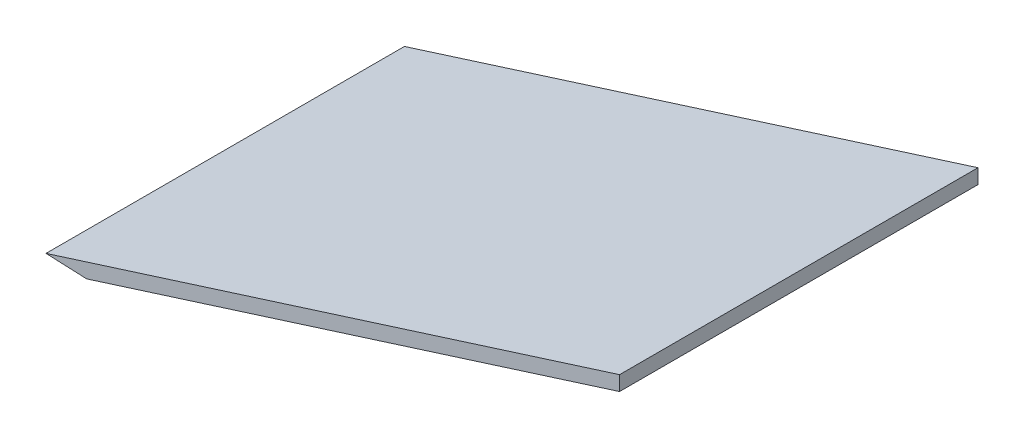
from build123d import *

# Parameters (mm, degrees)
BOSS_EXTRUDE1_DEPTH = 77


with BuildPart() as part:
    # Sketch2 → Boss-Extrude1 (new body)
    with BuildSketch(Plane.XY):
        Polygon((259.100000983, -157.771360612), (259.100002368, -154.6243331), (135.882594954, -193.670825903), (144.612166652, -194.051529893), align=None)
    extrude(amount=BOSS_EXTRUDE1_DEPTH)


solid = part.part
